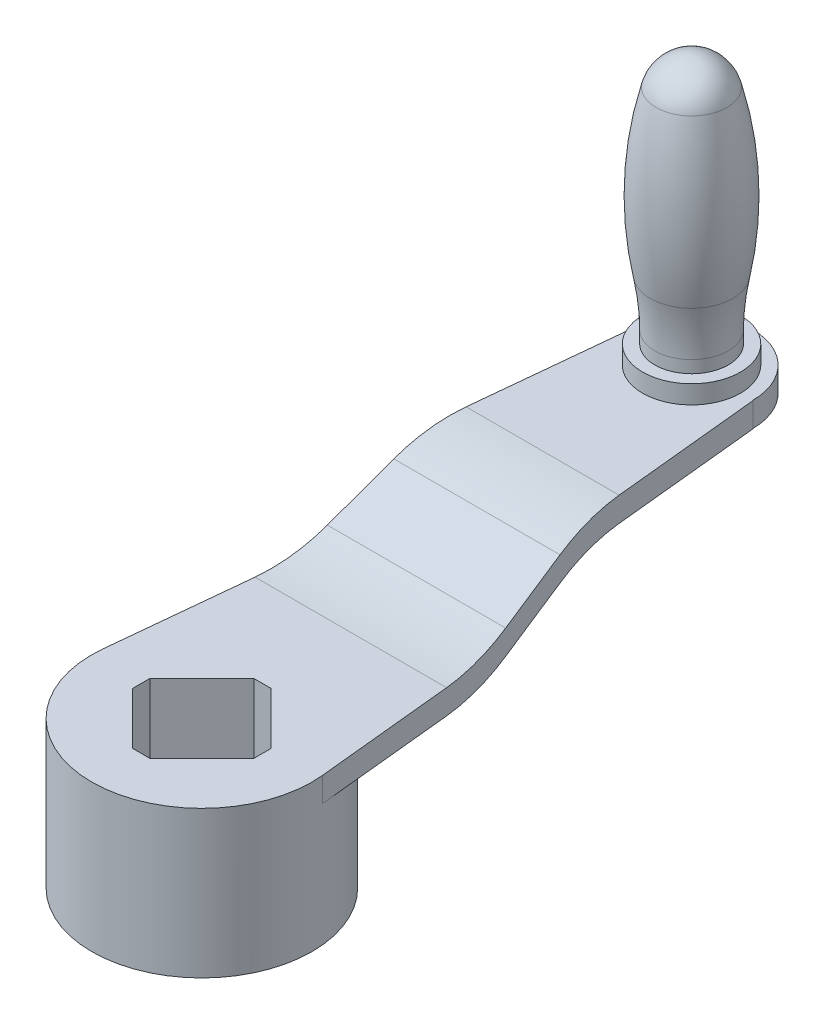
from build123d import *

# Parameters (mm, degrees)
IZIM2_R                     = 45
Y_KSEKLIK_EKSTR_ZYON1_DEPTH = 60
KES_EKSTR_ZYON1_DEPTH       = 88.464278423
Y_KSEKLIK_EKSTR_ZYON2_DEPTH = 45
KES_EKSTR_ZYON2_DEPTH       = 214.600093633
KES_EKSTR_ZYON4_DEPTH       = 229.907405513
Y_KSEKLIK_EKSTR_ZYON3_DEPTH = 10
IZIM10_R                    = 20
Y_KSEKLIK_EKSTR_ZYON4_DEPTH = 7.5


with BuildPart() as part:
    # Çizim2 → Yükseklik-Ekstrüzyon1 (new body)
    with BuildSketch(Plane(origin=(0, 0, 0), x_dir=(1, 0, 0), z_dir=(0, 1, 0))):
        Circle(IZIM2_R)
    extrude(amount=-Y_KSEKLIK_EKSTR_ZYON1_DEPTH)

    # Çizim5 → Kes-Ekstrüzyon1 (cut, through all)
    with BuildSketch(Plane(origin=(0, 0, 0), x_dir=(1, 0, 0), z_dir=(0, 1, 0))):
        Polygon((-24.748737342, 3.535533906), (-3.535533906, 24.748737342), (3.535533906, 24.748737342), (24.748737342, 3.535533906), (24.748737342, -3.535533906), (3.535533906, -24.748737342), (-3.535533906, -24.748737342), (-24.748737342, -3.535533906), align=None)
    extrude(amount=-KES_EKSTR_ZYON1_DEPTH, mode=Mode.SUBTRACT)

    # Çizim6 → Yükseklik-Ekstrüzyon2 (add, symmetric)
    with BuildSketch(Plane(origin=(0, 0, 0), x_dir=(0, 0, -1), z_dir=(1, 0, 0))):
        with BuildLine():
            Line((60.83592135, 0), (3.535533906, 0))
            Line((3.535533906, 0), (3.535533906, -10))
            Line((3.535533906, -10), (60.83592135, -10))
            ThreePointArc((60.83592135, -10), (74.621096583, -8.394939368), (87.66873708, -3.66563146))
            Line((87.66873708, -3.66563146), (112.33126292, 8.66563146))
            ThreePointArc((112.33126292, 8.66563146), (125.378903417, 13.394939368), (139.16407865, 15))
            Line((139.16407865, 15), (200, 15))
            Line((200, 15), (200, 25))
            Line((200, 25), (139.16407865, 25))
            ThreePointArc((139.16407865, 25), (125.378903417, 23.394939368), (112.33126292, 18.66563146))
            Line((112.33126292, 18.66563146), (87.66873708, 6.33436854))
            ThreePointArc((87.66873708, 6.33436854), (74.621096583, 1.605060632), (60.83592135, 0))
        make_face()
    extrude(amount=Y_KSEKLIK_EKSTR_ZYON2_DEPTH, both=True)

    # Çizim5<2> → Kes-Ekstrüzyon2 (cut, through all)
    with BuildSketch(Plane(origin=(0, 0, 0), x_dir=(1, 0, 0), z_dir=(0, 1, 0))):
        Polygon((-24.748737342, 3.535533906), (-3.535533906, 24.748737342), (3.535533906, 24.748737342), (24.748737342, 3.535533906), (24.748737342, -3.535533906), (3.535533906, -24.748737342), (-3.535533906, -24.748737342), (-24.748737342, -3.535533906), align=None)
    extrude(amount=-KES_EKSTR_ZYON2_DEPTH, mode=Mode.SUBTRACT)

    # Çizim7 → Kes-Ekstrüzyon4 (cut, through all)
    with BuildSketch(Plane(origin=(0, 41.850872841, 0), x_dir=(1, 0, 0), z_dir=(0, 1, 0))):
        with BuildLine():
            ThreePointArc((-45, 0), (-44.94357329, 2.252824878), (-44.77443467, 4.5))
            Line((-44.77443467, 4.5), (-25.125945381, 200))
            Line((-25.125945381, 200), (-45, 200))
            Line((-45, 200), (-45, 0))
        make_face()
        with BuildLine():
            Line((25.125945381, 200), (44.77443467, 4.5))
            ThreePointArc((44.77443467, 4.5), (44.94357329, 2.252824878), (45, 0))
            Line((45, 0), (45, 200))
            Line((45, 200), (25.125945381, 200))
        make_face()
    extrude(amount=-KES_EKSTR_ZYON4_DEPTH, mode=Mode.SUBTRACT)

    # Çizim9 → Yükseklik-Ekstrüzyon3 (add)
    with BuildSketch(Plane(origin=(0, 25, 0), x_dir=(1, 0, 0), z_dir=(0, 1, 0))):
        with BuildLine():
            Line((-25, 200), (25, 200))
            ThreePointArc((25, 200), (0, 225), (-25, 200))
        make_face()
    extrude(amount=-Y_KSEKLIK_EKSTR_ZYON3_DEPTH)

    # Çizim10 → Yükseklik-Ekstrüzyon4 (add)
    with BuildSketch(Plane(origin=(0, 25, 0), x_dir=(1, 0, 0), z_dir=(0, 1, 0))):
        with Locations((0, 200)):
            Circle(IZIM10_R)
    extrude(amount=Y_KSEKLIK_EKSTR_ZYON4_DEPTH)

    # Çizim12 → Döndür5 (revolve)
    with BuildSketch(Plane(origin=(0, 0, 0), x_dir=(0, 0, -1), z_dir=(1, 0, 0))):
        with BuildLine():
            ThreePointArc((214.501915582, 123.333333333), (209.151502609, 131.384864324), (200, 134.5))
            Line((200, 134.5), (200, 119.5))
            Line((200, 119.5), (200, 32.5))
            Line((200, 32.5), (215, 32.5))
            Line((215, 32.5), (215, 37.5))
            ThreePointArc((215, 37.5), (215.45962104, 47.262068061), (216.83441772, 56.937767437))
            ThreePointArc((216.83441772, 56.937767437), (219.390284523, 90.266309839), (214.501915582, 123.333333333))
        make_face()
    revolve(axis=Axis((0, 25, -200), (0, 1, 0)))


solid = part.part
